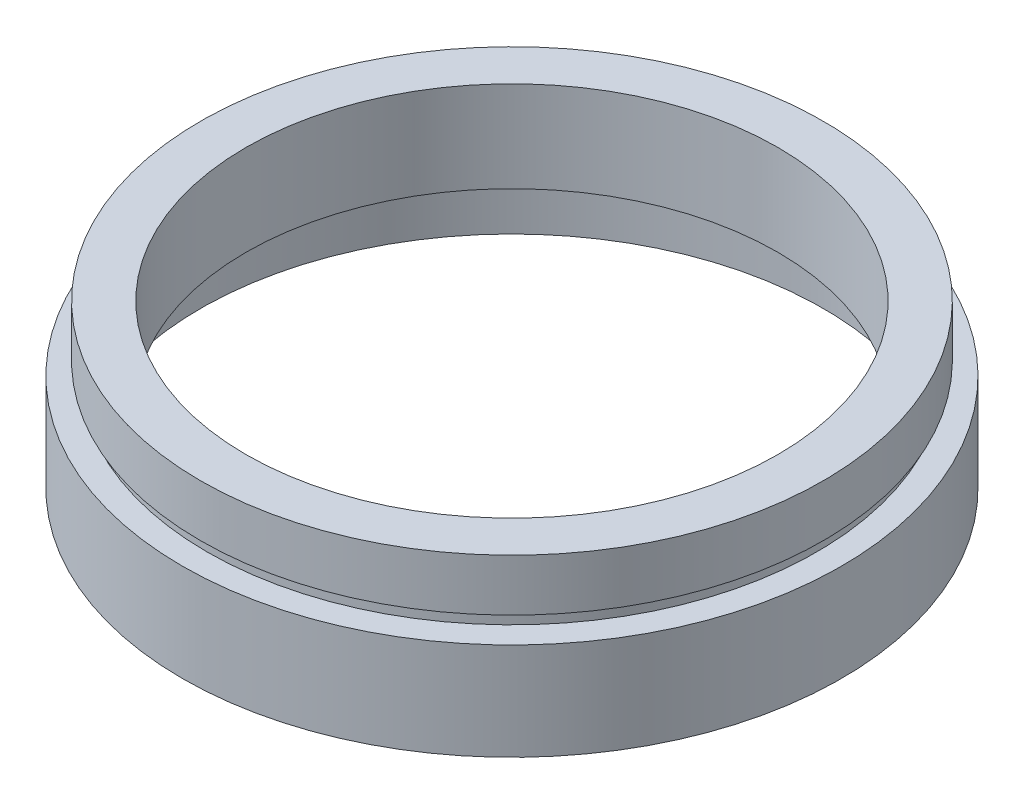
from build123d import *


with BuildPart() as part:
    # 草图1 → 旋转1 (revolve)
    with BuildSketch(Plane.XY, mode=Mode.PRIVATE) as revolve_1_sk:
        Polygon((20.5, 12.5), (24, 12.5), (24, 8.5), (23.5, 8.5), (23.5, 7.5), (25.4, 7.5), (25.4, 0), (24, 0), (24, 4.5), (24.1, 4.5), (24.1, 5.5), (20.5, 5.5), align=None)
    revolve(revolve_1_sk.sketch.rotate(Axis((0, 161.376166943, 0), (0, -1, 0)), 90), axis=Axis((0, 161.376166943, 0), (0, -1, 0)))  # turned: the seam where the file's is


solid = part.part
